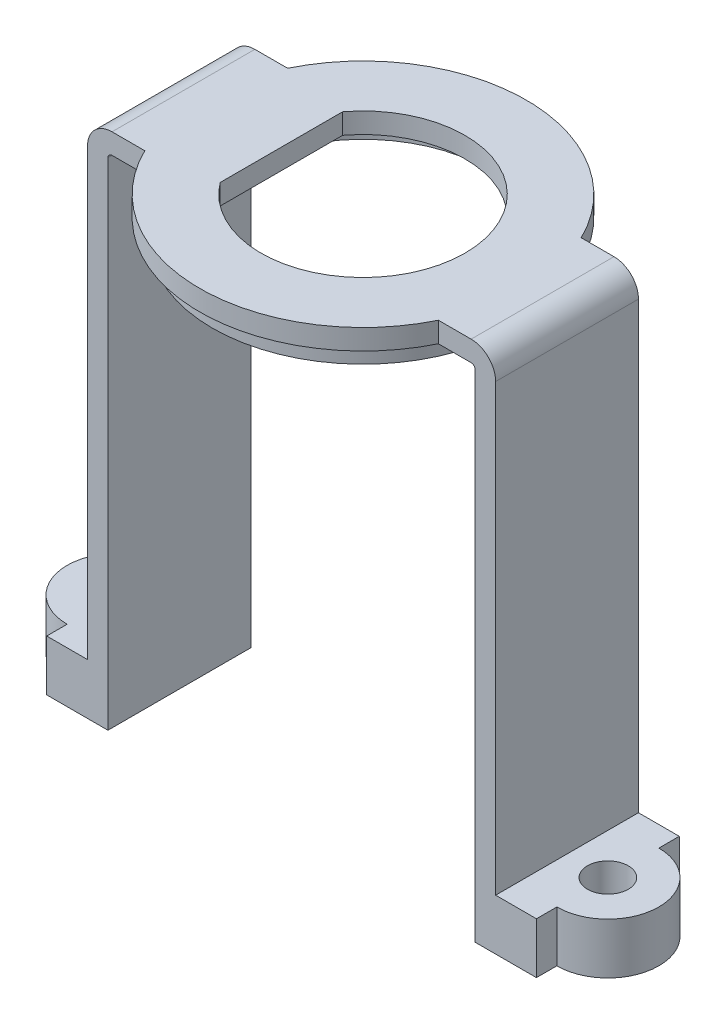
from build123d import *

# Parameters (mm, degrees)
BOSS_EXTRU_1_DEPTH      = 1
ESQUISSE2_R             = 7.375
ESQUISSE2_R_2           = 6.125
BOSS_EXTRU_2_DEPTH      = 1
ESQUISSE3_W             = 1
ESQUISSE3_H             = 22
BOSS_EXTRU_3_DEPTH      = 3.5
BOSS_EXTRU_3_DEPTH_BACK = 3.5
ESQUISSE4_R             = 1
BOSS_EXTRU_4_DEPTH      = 2.5
CONG_1_R                = 0.2
CONG_2_R                = 1.2


with BuildPart() as part:
    # Esquisse1 → Boss.-Extru.1 (new body)
    with BuildSketch(Plane(origin=(0, 0, 0), x_dir=(1, 0, 0), z_dir=(0, 1, 0))):
        with BuildLine():
            Line((7.193747285, 3.5), (10, 3.5))
            Line((10, 3.5), (10, -3.5))
            Line((10, -3.5), (7.193747285, -3.5))
            ThreePointArc((7.193747285, -3.5), (0, -8), (-7.193747285, -3.5))
            Line((-7.193747285, -3.5), (-10, -3.5))
            Line((-10, -3.5), (-10, 3.5))
            Line((-10, 3.5), (-7.193747285, 3.5))
            ThreePointArc((-7.193747285, 3.5), (0, 8), (7.193747285, 3.5))
        make_face()
        with BuildLine():
            Line((-4, 3), (-4, -3))
            ThreePointArc((-4, -3), (5, 0), (-4, 3))
        make_face(mode=Mode.SUBTRACT)
    extrude(amount=-BOSS_EXTRU_1_DEPTH)

    # Esquisse2 → Boss.-Extru.2 (add)
    with BuildSketch(Plane.XZ.offset(1)):
        with Locations(Location((0, 0, 0), (0, 0, 90))):  # turned: the seam where the file's is
            Circle(ESQUISSE2_R)
        with Locations(Location((0, 0, 0), (0, 0, 270))):  # turned: the seam where the file's is
            Circle(ESQUISSE2_R_2, mode=Mode.SUBTRACT)
    extrude(amount=BOSS_EXTRU_2_DEPTH)

    # Esquisse3 → Boss.-Extru.3 (add, two sides)
    with BuildSketch(Plane.XY) as boss_extru_3_sk:
        with Locations((-9.5, -12)):
            Rectangle(ESQUISSE3_W, ESQUISSE3_H)
        with Locations((9.5, -12)):
            Rectangle(ESQUISSE3_W, ESQUISSE3_H)
    extrude(amount=BOSS_EXTRU_3_DEPTH)
    extrude(boss_extru_3_sk.sketch, amount=-BOSS_EXTRU_3_DEPTH_BACK)

    # Esquisse4 → Boss.-Extru.4 (add)
    with BuildSketch(Plane.XZ.offset(23)):
        with BuildLine():
            Line((-12, 2.5), (-12, 3.5))
            Line((-12, 3.5), (-9, 3.5))
            Line((-9, 3.5), (-9, -3.5))
            Line((-9, -3.5), (-12, -3.5))
            Line((-12, -3.5), (-12, -2.5))
            ThreePointArc((-12, -2.5), (-14.5, 0), (-12, 2.5))
        make_face()
        with Locations(Location((-12, 0, 0), (0, 0, 270))):  # turned: the seam where the file's is
            Circle(ESQUISSE4_R, mode=Mode.SUBTRACT)
        with BuildLine():
            Line((12, 2.5), (12, 3.5))
            Line((12, 3.5), (9, 3.5))
            Line((9, 3.5), (9, -3.5))
            Line((9, -3.5), (12, -3.5))
            Line((12, -3.5), (12, -2.5))
            ThreePointArc((12, -2.5), (14.5, 0), (12, 2.5))
        make_face()
        with Locations(Location((12, 0, 0), (0, 0, 90))):  # turned: the seam where the file's is
            Circle(ESQUISSE4_R, mode=Mode.SUBTRACT)
    extrude(amount=BOSS_EXTRU_4_DEPTH)

    # Cong_1
    cong_1_edges = [part.edges().sort_by_distance(p)[0] for p in [
        (-9, -1, 0),
        (9, -1, 0),
    ]]
    fillet(cong_1_edges, radius=CONG_1_R)

    # Cong_2
    cong_2_edges = [part.edges().sort_by_distance(p)[0] for p in [
        (-10, 0, 0),
        (10, 0, 0),
    ]]
    fillet(cong_2_edges, radius=CONG_2_R)


solid = part.part
